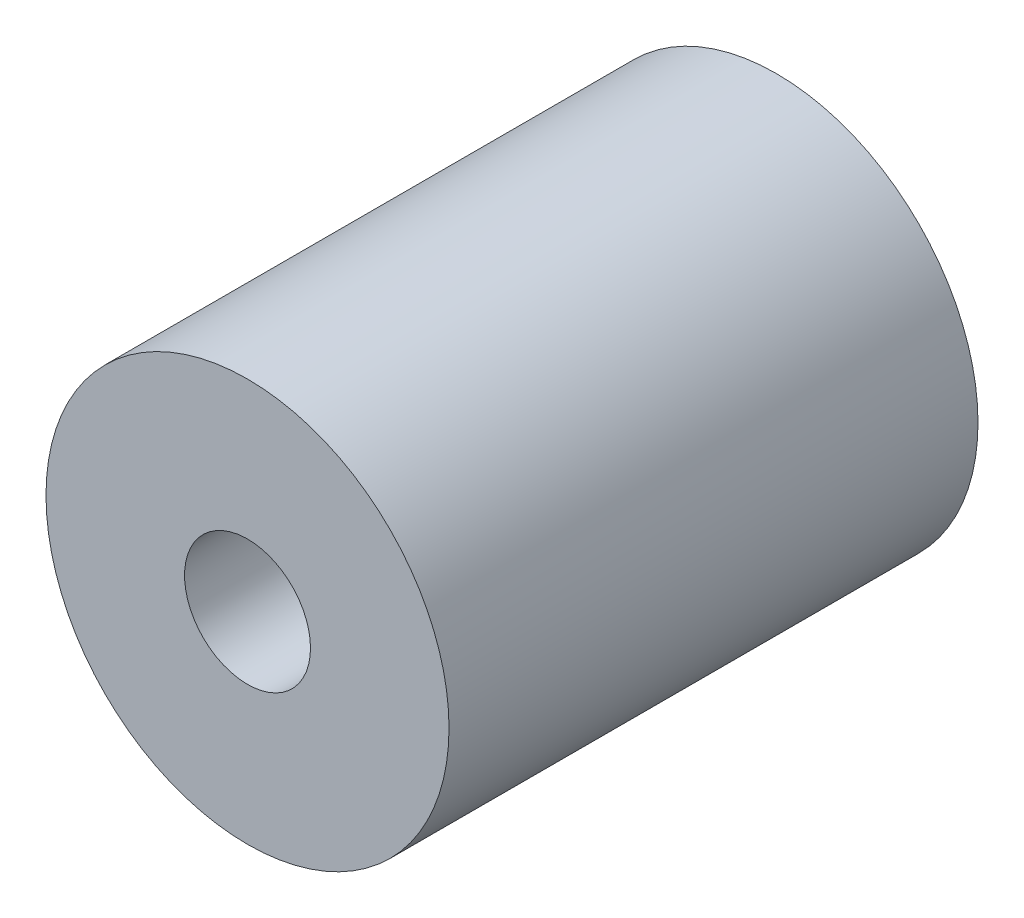
from build123d import *

# Parameters (mm, degrees)
SZKIC1_R                    = 16
SZKIC1_R_2                  = 5
DODANIE_WYCI_GNI_CIE1_DEPTH = 42


with BuildPart() as part:
    # Szkic1 → Dodanie-wyciągnięcie1 (new body)
    with BuildSketch(Plane.XY):
        Circle(SZKIC1_R)
        Circle(SZKIC1_R_2, mode=Mode.SUBTRACT)
    extrude(amount=DODANIE_WYCI_GNI_CIE1_DEPTH)


solid = part.part
